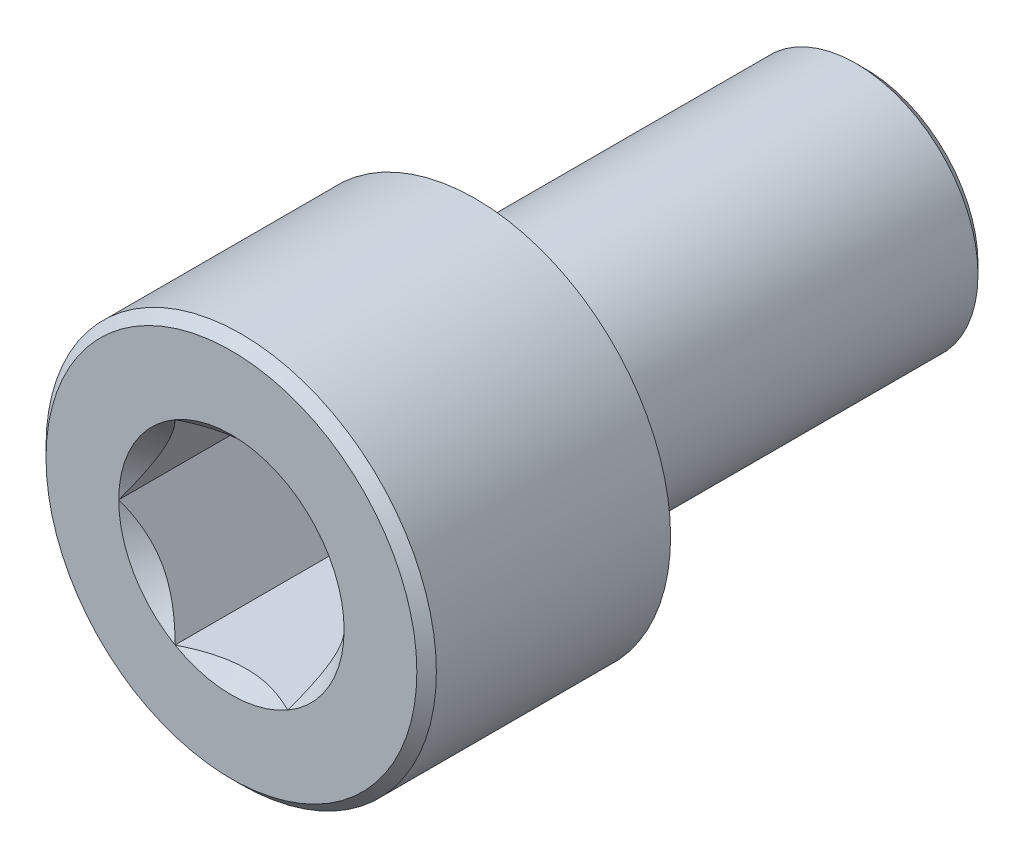
from build123d import *

# Parameters (mm, degrees)
SKETCH_1_R          = 4
EXTRUDE_1_DEPTH     = 5
CUT_EXTRUDE_1_DEPTH = 3.4
SKETCH_3_R          = 2.309401077
CUT_EXTRUDE_2_DEPTH = 3.4
CUT_EXTRUDE_2_DRAFT = -45
CHAMFER_1_SIZE      = 0.2
SKETCH_4_R          = 2.5
EXTRUDE_2_DEPTH     = 8
CHAMFER_2_SIZE      = 0.2


with BuildPart() as part:
    # Эскиз1 → Бобышка-Вытянуть1 (new body)
    with BuildSketch(Plane.XY):
        Circle(SKETCH_1_R)
    extrude(amount=EXTRUDE_1_DEPTH)

    # Эскиз2 → Вырез-Вытянуть1 (cut)
    with BuildSketch(Plane.XY.offset(5)):
        Polygon((2.309401077, 0), (1.154700538, 2), (-1.154700538, 2), (-2.309401077, 0), (-1.154700538, -2), (1.154700538, -2), align=None)
    extrude(amount=-CUT_EXTRUDE_1_DEPTH, mode=Mode.SUBTRACT)


with BuildPart() as cut_extrude_2_tool:
    # Эскиз3 → Вырез-Вытянуть2 (with draft: the straight prism first)
    with BuildSketch(Plane.XY.offset(5)):
        Circle(SKETCH_3_R)
    extrude(amount=-CUT_EXTRUDE_2_DEPTH)
    # Вырез-Вытянуть2: the draft: its side faces are tilted about the plane it starts from
    cut_extrude_2_sides = [cut_extrude_2_tool.faces().sort_by_distance(p)[0] for p in [
        (-2.309401077, 0, 3.3),
    ]]
    draft(cut_extrude_2_sides, Plane.XY.offset(5), CUT_EXTRUDE_2_DRAFT)


with BuildPart() as part_1:
    add(part.part)

    # Вырез-Вытянуть2: cut by cut_extrude_2_tool
    add(cut_extrude_2_tool.part, mode=Mode.SUBTRACT)

    # Фаска1
    chamfer_1_edges = [part_1.edges().sort_by_distance(p)[0] for p in [
        (-4, 0, 5),
    ]]
    chamfer(chamfer_1_edges, length=CHAMFER_1_SIZE)

    # Эскиз4 → Бобышка-Вытянуть2 (add)
    with BuildSketch(Plane(origin=(0, 0, 0), x_dir=(-1, 0, 0), z_dir=(0, 0, -1))):
        Circle(SKETCH_4_R)
    extrude(amount=EXTRUDE_2_DEPTH)

    # Фаска2
    chamfer_2_edges = [part_1.edges().sort_by_distance(p)[0] for p in [
        (2.5, 0, -8),
    ]]
    chamfer(chamfer_2_edges, length=CHAMFER_2_SIZE)


solid = part_1.part
